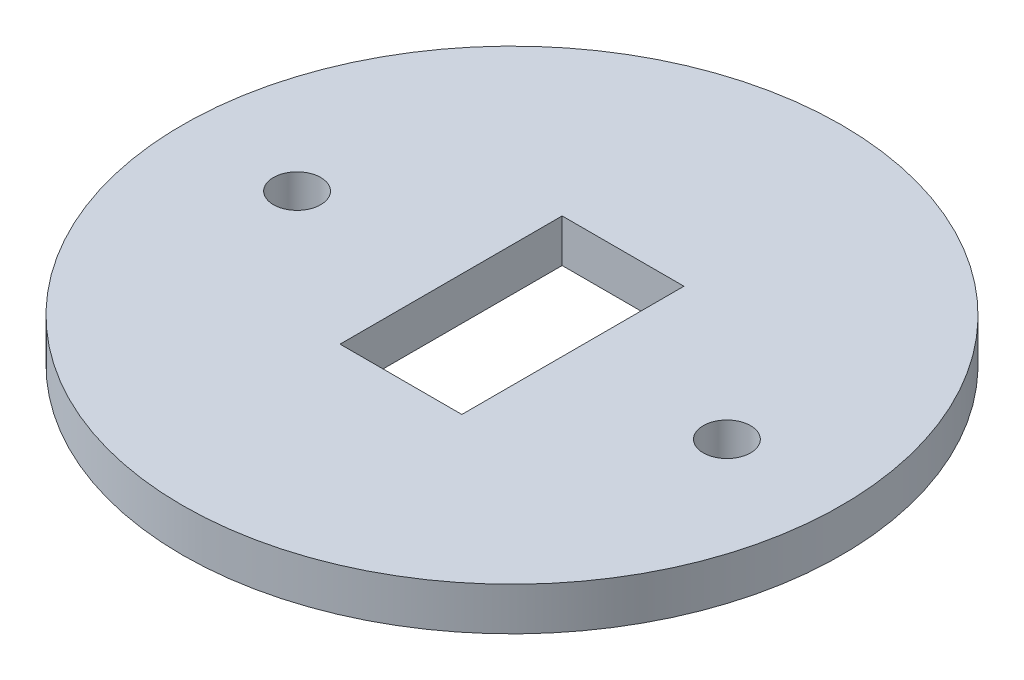
from build123d import *

# Parameters (mm, degrees)
SKETCH1_R           = 23
SKETCH1_R_2         = 1.65
SKETCH1_W           = 8.5
SKETCH1_H           = 15.5
BOSS_EXTRUDE1_DEPTH = 3


with BuildPart() as part:
    # Sketch1 → Boss-Extrude1 (new body)
    with BuildSketch(Plane(origin=(0, 0, 0), x_dir=(1, 0, 0), z_dir=(0, 1, 0))):
        Circle(SKETCH1_R)
        with Locations((-15, 0)):
            Circle(SKETCH1_R_2, mode=Mode.SUBTRACT)
        with Locations((15, 0)):
            Circle(SKETCH1_R_2, mode=Mode.SUBTRACT)
        Rectangle(SKETCH1_W, SKETCH1_H, mode=Mode.SUBTRACT)
    extrude(amount=BOSS_EXTRUDE1_DEPTH)


solid = part.part
